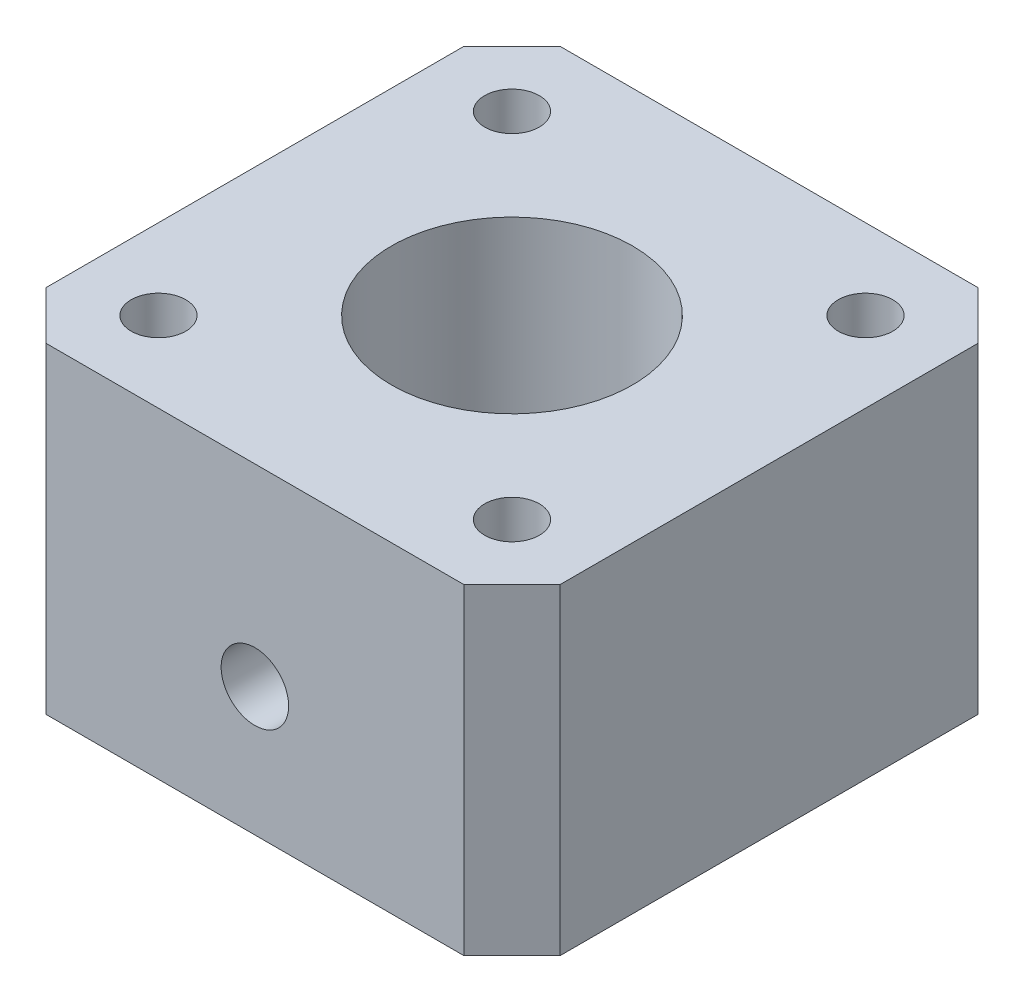
from build123d import *

# Parameters (mm, degrees)
SKETCH1_R                      = 7.5
BOSS_EXTRUDE1_DEPTH            = 20
M5X0_8_TAPPED_HOLE1_D          = 4.2
M5X0_8_TAPPED_HOLE1_DEPTH      = 15.999
M5X0_8_TAPPED_HOLE1_TIP        = 1.2618073
CBORE_FOR_M3_SHCS1_D           = 3.4
CBORE_FOR_M3_SHCS1_CBORE_D     = 6.5
CBORE_FOR_M3_SHCS1_CBORE_DEPTH = 3


with BuildPart() as part:
    # Sketch1 → Boss-Extrude1 (new body)
    with BuildSketch(Plane(origin=(0, 0, 0), x_dir=(1, 0, 0), z_dir=(0, 1, 0))):
        Polygon((-16, 13), (-13, 16), (13, 16), (16, 13), (16, -13), (13, -16), (-13, -16), (-16, -13), align=None)
        Circle(SKETCH1_R, mode=Mode.SUBTRACT)
    extrude(amount=BOSS_EXTRUDE1_DEPTH)

    # M5x0.8 Tapped Hole1
    with Locations(Plane.XY.offset(16)):
        with Locations((0, 8)):
            Hole(M5X0_8_TAPPED_HOLE1_D / 2, depth=M5X0_8_TAPPED_HOLE1_DEPTH)
            with Locations((0, 0, -(M5X0_8_TAPPED_HOLE1_DEPTH + M5X0_8_TAPPED_HOLE1_TIP / 2))):  # 118° drill point
                Cone(0, M5X0_8_TAPPED_HOLE1_D / 2, M5X0_8_TAPPED_HOLE1_TIP, mode=Mode.SUBTRACT)

    # CBORE for M3 SHCS1 (through all)
    with Locations(Plane(origin=(0, 0, 0), x_dir=(-1, 0, 0), z_dir=(0, -1, 0))):
        with Locations((-11, 11), (11, 11), (11, -11), (-11, -11)):
            CounterBoreHole(CBORE_FOR_M3_SHCS1_D / 2, CBORE_FOR_M3_SHCS1_CBORE_D / 2, CBORE_FOR_M3_SHCS1_CBORE_DEPTH)


solid = part.part
